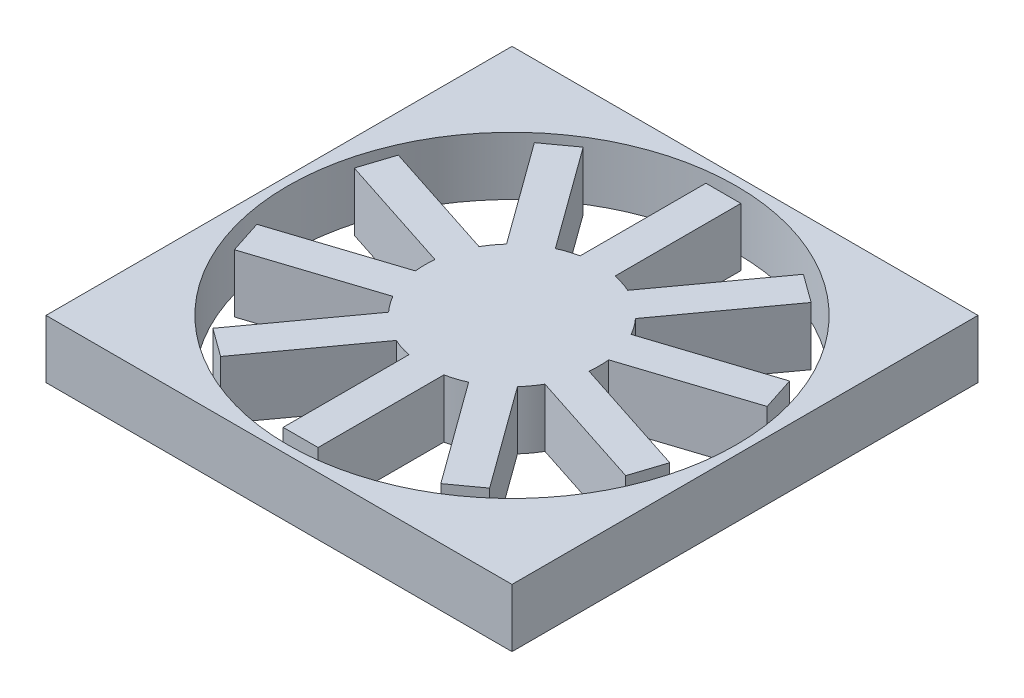
from build123d import *

# Parameters (mm, degrees)
SKETCH1_W           = 80
SKETCH1_H           = 80
BOSS_EXTRUDE1_DEPTH = 10
SKETCH2_R           = 38.5
SKETCH2_R_2         = 15
CUT_EXTRUDE1_DEPTH  = 10
SKETCH3_W           = 6
SKETCH3_H           = 26.941084331
BOSS_EXTRUDE2_DEPTH = 10


with BuildPart() as part:
    # Sketch1 → Boss-Extrude1 (new body)
    with BuildSketch(Plane(origin=(0, 0, 0), x_dir=(1, 0, 0), z_dir=(0, 1, 0))):
        with Locations((11.36915078, -0.485268631)):
            Rectangle(SKETCH1_W, SKETCH1_H)
    extrude(amount=BOSS_EXTRUDE1_DEPTH)

    # Sketch2 → Cut-Extrude1 (cut)
    with BuildSketch(Plane(origin=(0, 10, 0), x_dir=(1, 0, 0), z_dir=(0, 1, 0))):
        with Locations((11.36915078, -0.485268631)):
            Circle(SKETCH2_R)
        with Locations((11.36915078, -0.485268631)):
            Circle(SKETCH2_R_2, mode=Mode.SUBTRACT)
    extrude(amount=-CUT_EXTRUDE1_DEPTH, mode=Mode.SUBTRACT)

    # Sketch3 → Boss-Extrude2 (add)
    with BuildSketch(Plane(origin=(0, 10, 0), x_dir=(1, 0, 0), z_dir=(0, 1, 0))):
        Polygon((-12.38846571, 27.11038033), (3.447106341, 5.314585258), (8.301208307, 8.841296772), (-7.534363744, 30.637091843), align=None)
        with Locations((11.36915078, 22.333914785)):
            Rectangle(SKETCH3_W, SKETCH3_H)
        Polygon((-24.071480193, 7.875703746), (1.551013617, -0.449549159), (3.405115583, 5.256789939), (-22.217378227, 13.582042844), align=None)
        Polygon((-22.217378227, -14.552580106), (3.405115583, -6.227327201), (1.551013617, -0.520988103), (-24.071480193, -8.846241008), align=None)
        Polygon((-7.534363744, -31.607629105), (8.301208307, -9.811834034), (3.447106341, -6.28512252), (-12.38846571, -28.080917591), align=None)
        with Locations((11.36915078, -23.304452047)):
            Rectangle(SKETCH3_W, SKETCH3_H)
        Polygon((35.12676727, -28.080917591), (19.291195219, -6.28512252), (14.437093253, -9.811834034), (30.272665304, -31.607629105), align=None)
        Polygon((46.809781753, -8.846241008), (21.187287943, -0.520988103), (19.333185977, -6.227327201), (44.955679786, -14.552580106), align=None)
        Polygon((44.955679786, 13.582042844), (19.333185977, 5.256789939), (21.187287943, -0.449549159), (46.809781753, 7.875703746), align=None)
        Polygon((30.272665304, 30.637091843), (14.437093253, 8.841296772), (19.291195219, 5.314585258), (35.12676727, 27.11038033), align=None)
    extrude(amount=-BOSS_EXTRUDE2_DEPTH)


solid = part.part
